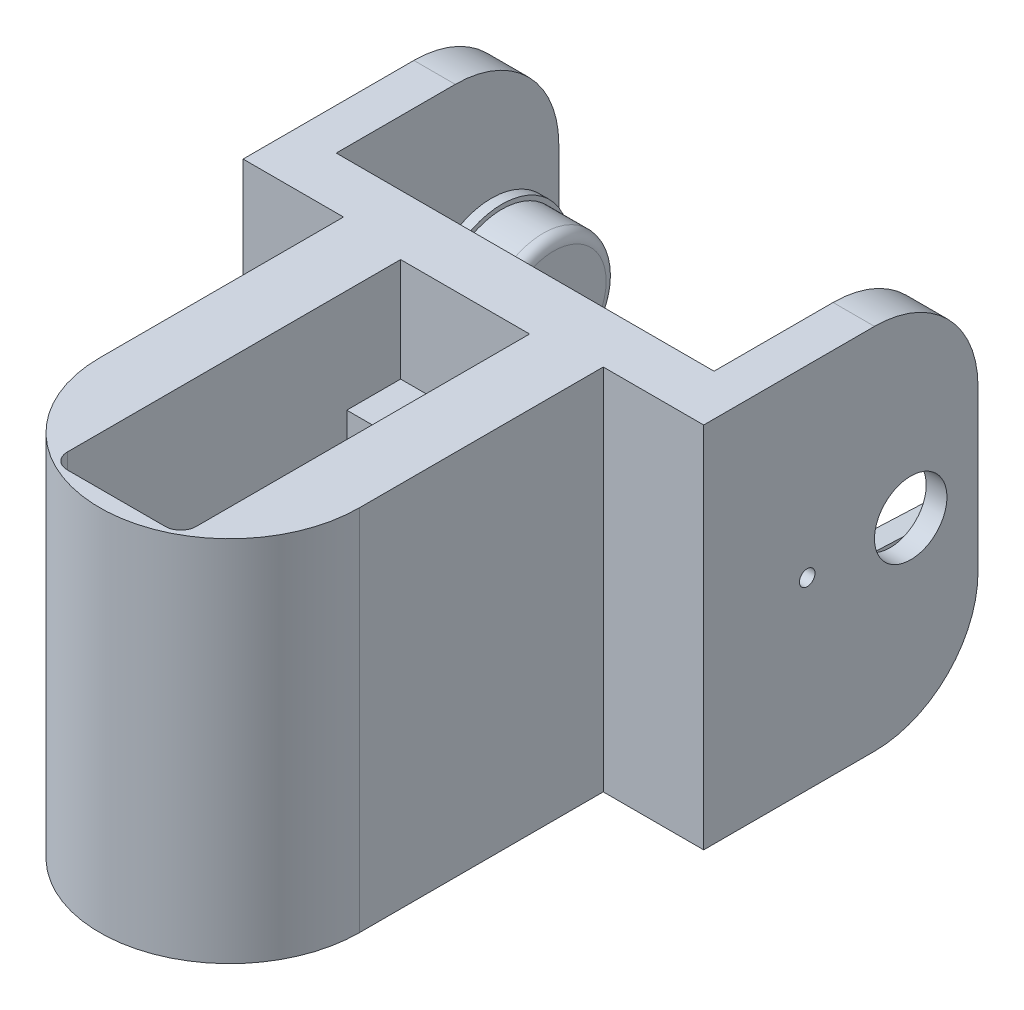
from build123d import *

# Parameters (mm, degrees)
SKETCH4_W                = 12.46
SKETCH4_H                = 17.25
BOSS_EXTRUDE3_DEPTH      = 6
SKETCH8_R                = 12.546781182
SKETCH8_R_2              = 11.15
BOSS_EXTRUDE6_DEPTH      = 8.3
BOSS_EXTRUDE6_DEPTH_BACK = 17.25
BOSS_EXTRUDE4_DEPTH      = 17.25
SKETCH6_R                = 0.75
CUT_EXTRUDE1_DEPTH       = 5
CHAMFER1_SIZE            = 0.5
CHAMFER1_SIZE2           = 0.866025404
SKETCH10_W               = 12.46
SKETCH10_H               = 23.7
CUT_EXTRUDE3_DEPTH       = 17.25
BOSS_EXTRUDE7_DEPTH      = 8.3
BOSS_EXTRUDE9_DEPTH      = 10
SKETCH20_R               = 11.15
SKETCH20_R_2             = 7.15
BOSS_EXTRUDE11_DEPTH     = 8.3
SKETCH21_R               = 10.15
SKETCH21_R_2             = 7.15
CUT_EXTRUDE7_DEPTH       = 1.3
SKETCH11_W               = 10
SKETCH11_H               = 2
CUT_EXTRUDE4_DEPTH       = 23.7
CUT_EXTRUDE8_REACH       = 37.55
SKETCH25_W               = 12.46
SKETCH25_H               = 6
BOSS_EXTRUDE10_DEPTH     = 35.55
SKETCH18_W               = 21.5
SKETCH18_H               = 11.438292938
CUT_EXTRUDE5_DEPTH       = 2
SKETCH19_R               = 3.5
CUT_EXTRUDE6_DEPTH       = 43.5
CUT_EXTRUDE6_DEPTH_BACK  = 3
FILLET1_R                = 10
SKETCH22_R               = 6.5
BOSS_EXTRUDE12_DEPTH     = 5
SKETCH23_R               = 6.075
BOSS_EXTRUDE13_DEPTH     = 5
FILLET2_R                = 1
BOSS_EXTRUDE14_DEPTH     = 2
CUT_EXTRUDE9_REACH       = 46.5
SKETCH27_R               = 0.75


with BuildPart() as part:
    # Sketch4 → Boss-Extrude3 (new body)
    with BuildSketch(Plane.XY):
        with Locations((0, -1.35)):
            Rectangle(SKETCH4_W, SKETCH4_H)
    extrude(amount=BOSS_EXTRUDE3_DEPTH)



with BuildPart() as body_2:
    # Sketch8 → Boss-Extrude6 (new body, two sides)
    with BuildSketch(Plane(origin=(0, -9.975, 0), x_dir=(-1, 0, 0), z_dir=(0, -1, 0))) as boss_extrude6_sk:
        with Locations((0, -23.55)):
            Circle(SKETCH8_R)
        with Locations((0, -23.55)):
            Circle(SKETCH8_R_2, mode=Mode.SUBTRACT)
    extrude(amount=BOSS_EXTRUDE6_DEPTH)
    extrude(boss_extrude6_sk.sketch, amount=-BOSS_EXTRUDE6_DEPTH_BACK)


with BuildPart() as part_1:
    add(part.part)

    add(body_2.part)  # Boss-Extrude4 merges body 2
    # Sketch5 → Boss-Extrude4 (add)
    with BuildSketch(Plane(origin=(0, 7.275, 0), x_dir=(1, 0, 0), z_dir=(0, 1, 0))):
        with BuildLine():
            Line((12.546781182, -23.55), (12.546781182, 0))
            Line((12.546781182, 0), (6.23, 0))
            Line((6.23, 0), (6.23, -29.7))
            Line((6.23, -29.7), (-6.23, -29.7))
            Line((-6.23, -29.7), (-6.23, 0))
            Line((-6.23, 0), (-12.546781182, 0))
            Line((-12.546781182, 0), (-12.546781182, -23.55))
            ThreePointArc((-12.546781182, -23.55), (0, -36.096781182), (12.546781182, -23.55))
        make_face()
    extrude(amount=-BOSS_EXTRUDE4_DEPTH)

    # Sketch6 → Cut-Extrude1 (cut)
    with BuildSketch(Plane(origin=(0, 7.275, 0), x_dir=(1, 0, 0), z_dir=(0, 1, 0))):
        with Locations((0, -3.6)):
            Circle(SKETCH6_R)
        with Locations((0, -32.1)):
            Circle(SKETCH6_R)
    extrude(amount=-CUT_EXTRUDE1_DEPTH, mode=Mode.SUBTRACT)

    # Chamfer1
    chamfer1_edges = [part_1.edges().sort_by_distance(p)[0] for p in [
        (-0.75, 7.275, 3.6),
        (-0.75, 7.275, 32.1),
    ]]
    chamfer1_side = [part_1.faces().sort_by_distance(p)[0] for p in [
        (0, 7.275, 35.657160381),
    ]]
    chamfer(chamfer1_edges, length=CHAMFER1_SIZE, length2=CHAMFER1_SIZE2, reference=chamfer1_side[0])

    # Sketch10 → Cut-Extrude3 (cut)
    with BuildSketch(Plane(origin=(0, 7.275, 0), x_dir=(1, 0, 0), z_dir=(0, 1, 0))):
        with Locations((0, -17.85)):
            Rectangle(SKETCH10_W, SKETCH10_H)
    extrude(amount=-CUT_EXTRUDE3_DEPTH, mode=Mode.SUBTRACT)

    # Sketch13 → Boss-Extrude7 (add)
    with BuildSketch(Plane.XZ.offset(18.275)):
        with BuildLine():
            Line((-12.546781182, 23.55), (-12.546781182, 0))
            Line((-12.546781182, 0), (12.546781182, 0))
            Line((12.546781182, 0), (12.546781182, 23.55))
            ThreePointArc((12.546781182, 23.55), (0, 11.003218818), (-12.546781182, 23.55))
        make_face()
    extrude(amount=-BOSS_EXTRUDE7_DEPTH)

    # Sketch15 → Boss-Extrude9 (add)
    with BuildSketch(Plane(origin=(0, 7.275, 0), x_dir=(1, 0, 0), z_dir=(0, 1, 0))):
        with BuildLine():
            Line((-12.546781182, 0), (12.546781182, 0))
            Line((12.546781182, 0), (12.546781182, -23.55))
            ThreePointArc((12.546781182, -23.55), (0, -36.096781182), (-12.546781182, -23.55))
            Line((-12.546781182, -23.55), (-12.546781182, 0))
        make_face()
        with BuildLine():
            Line((-6.23, -0.8), (6.23, -0.8))
            Line((6.23, -0.8), (6.23, -33))
            ThreePointArc((6.23, -33), (5.790660172, -34.060660172), (4.73, -34.5))
            Line((4.73, -34.5), (-4.73, -34.5))
            ThreePointArc((-4.73, -34.5), (-5.790660172, -34.060660172), (-6.23, -33))
            Line((-6.23, -33), (-6.23, -0.8))
        make_face(mode=Mode.SUBTRACT)
    extrude(amount=BOSS_EXTRUDE9_DEPTH)

    # Sketch20 → Boss-Extrude11 (add)
    with BuildSketch(Plane.XZ.offset(18.275)):
        with Locations((0, 23.55)):
            Circle(SKETCH20_R)
        with Locations((0, 23.55)):
            Circle(SKETCH20_R_2, mode=Mode.SUBTRACT)
    extrude(amount=-BOSS_EXTRUDE11_DEPTH)

    # Sketch21 → Cut-Extrude7 (cut)
    with BuildSketch(Plane.XZ.offset(18.275)):
        with Locations((0, 23.55)):
            Circle(SKETCH21_R)
        with Locations((0, 23.55)):
            Circle(SKETCH21_R_2, mode=Mode.SUBTRACT)
    extrude(amount=-CUT_EXTRUDE7_DEPTH, mode=Mode.SUBTRACT)

    # Sketch11 → Cut-Extrude4 (cut)
    with BuildSketch(Plane.XY.offset(29.7)):
        with Locations((0, -10.975)):
            Rectangle(SKETCH11_W, SKETCH11_H)
    extrude(amount=-CUT_EXTRUDE4_DEPTH, mode=Mode.SUBTRACT)

    # Sketch25 → Cut-Extrude8 (cut, up to next)
    with BuildSketch(Plane.XZ.offset(18.275), mode=Mode.PRIVATE) as cut_extrude8_sk1:
        with Locations((0, 9)):
            Rectangle(SKETCH25_W, SKETCH25_H)
    cut_extrude8_tool1 = extrude(cut_extrude8_sk1.sketch, amount=-CUT_EXTRUDE8_REACH, mode=Mode.PRIVATE) & part_1.part
    add(cut_extrude8_tool1.solids().sort_by_distance((0, -18.275, 9))[0], mode=Mode.SUBTRACT)

    # Sketch17 → Boss-Extrude10 (add)
    with BuildSketch(Plane(origin=(0, 17.275, 0), x_dir=(1, 0, 0), z_dir=(0, 1, 0))):
        Polygon((22.25, 26.5), (22.25, 0), (-22.25, 0), (-22.25, 26.5), (-18.25, 26.5), (-18.25, 5), (18.25, 5), (18.25, 26.5), align=None)
    extrude(amount=-BOSS_EXTRUDE10_DEPTH)

    # Sketch18 → Cut-Extrude5 (cut)
    with BuildSketch(Plane.ZY.offset(-18.25)):
        with Locations((-15.75, -0.5)):
            Rectangle(SKETCH18_W, SKETCH18_H)
    extrude(amount=-CUT_EXTRUDE5_DEPTH, mode=Mode.SUBTRACT)

    # Sketch19 → Cut-Extrude6 (cut, two sides)
    with BuildSketch(Plane.ZY.offset(-20.25)) as cut_extrude6_sk:
        with Locations((-20, -0.5)):
            Circle(SKETCH19_R)
    extrude(amount=CUT_EXTRUDE6_DEPTH, mode=Mode.SUBTRACT)
    extrude(cut_extrude6_sk.sketch, amount=-CUT_EXTRUDE6_DEPTH_BACK, mode=Mode.SUBTRACT)

    # Fillet1
    fillet1_edges = [part_1.edges().sort_by_distance(p)[0] for p in [
        (20.25, 17.275, -26.5),
        (-20.25, 17.275, -26.5),
        (-20.25, -18.275, -26.5),
        (20.25, -18.275, -26.5),
    ]]
    fillet(fillet1_edges, radius=FILLET1_R)

    # Sketch22 → Boss-Extrude12 (add)
    with BuildSketch(Plane.ZY.offset(22.25)):
        with Locations((-20, -0.5)):
            Circle(SKETCH22_R)
    extrude(amount=-BOSS_EXTRUDE12_DEPTH)

    # Sketch23 → Boss-Extrude13 (add)
    with BuildSketch(Plane(origin=(-17.25, 0, 0), x_dir=(0, 0, -1), z_dir=(1, 0, 0))):
        with Locations((20, -0.5)):
            Circle(SKETCH23_R)
    extrude(amount=BOSS_EXTRUDE13_DEPTH)

    # Fillet2
    fillet2_edges = [part_1.edges().sort_by_distance(p)[0] for p in [
        (-12.25, -0.5, -13.925),
    ]]
    fillet(fillet2_edges, radius=FILLET2_R)

    # Sketch26 → Boss-Extrude14 (add)
    with BuildSketch(Plane.ZY.offset(-20.25)):
        Polygon((-5, 2), (-20, 2.6585), (-26.5, 2.94385), (-26.5, 5.219146469), (-5, 5.219146469), align=None)
        Polygon((-20, -3.6585), (-5, -3), (-5, -6.219146469), (-26.5, -6.219146469), (-26.5, -3.94385), align=None)
    extrude(amount=BOSS_EXTRUDE14_DEPTH)

    # Sketch27 → Cut-Extrude9 (cut, up to next)
    with BuildSketch(Plane(origin=(22.25, 0, 0), x_dir=(0, 0, -1), z_dir=(1, 0, 0)), mode=Mode.PRIVATE) as cut_extrude9_sk1:
        with Locations((10, -0.5)):
            Circle(SKETCH27_R)
    cut_extrude9_tool1 = extrude(cut_extrude9_sk1.sketch, amount=-CUT_EXTRUDE9_REACH, mode=Mode.PRIVATE) & part_1.part
    add(cut_extrude9_tool1.solids().sort_by_distance((22.25, -0.5, -10))[0], mode=Mode.SUBTRACT)


solid = part_1.part
